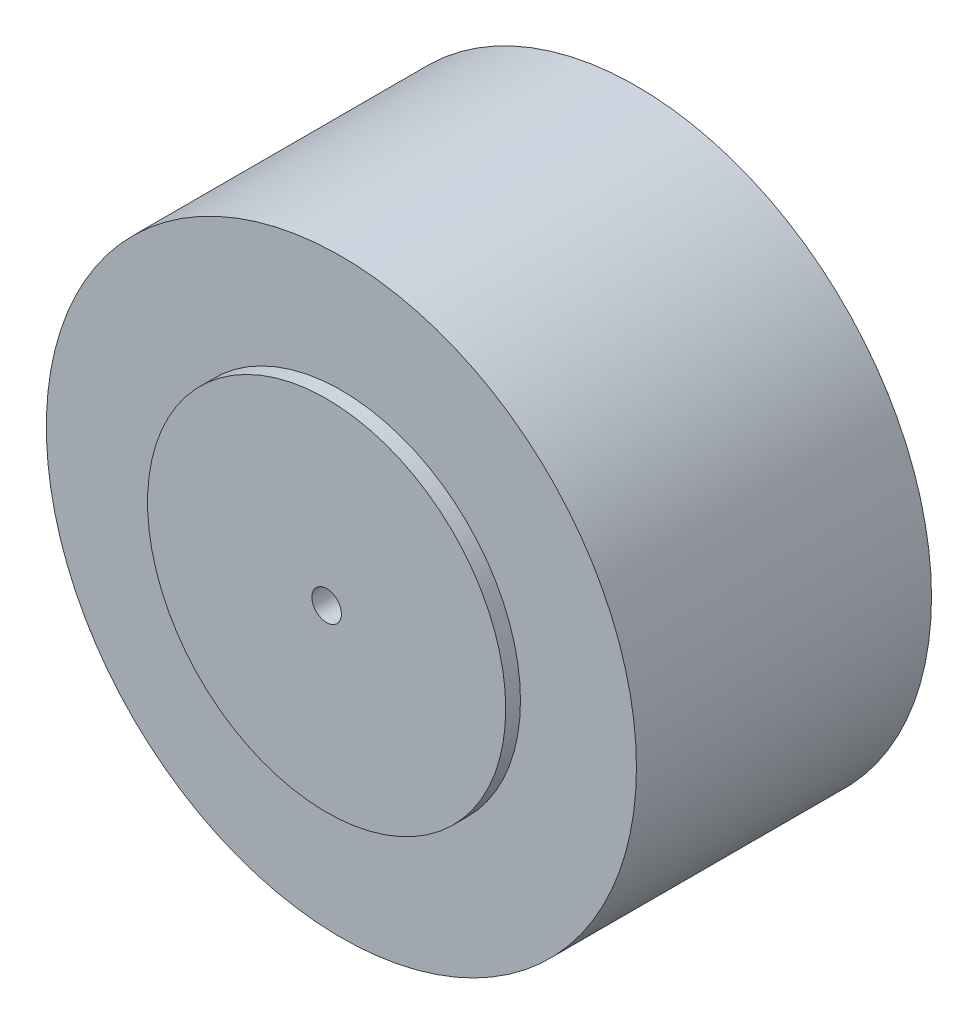
from build123d import *

# Parameters (mm, degrees)
SKETCH1_R           = 12.7
BOSS_EXTRUDE1_DEPTH = 12.7
SKETCH2_R           = 7.70834565
BOSS_EXTRUDE2_DEPTH = 0.635
SKETCH3_R           = 7.677981209
BOSS_EXTRUDE3_DEPTH = 0.635
SKETCH4_R           = 0.635
CUT_EXTRUDE1_DEPTH  = 1.27
SKETCH5_R           = 0.635
CUT_EXTRUDE2_DEPTH  = 1.27


with BuildPart() as part:
    # Sketch1 → Boss-Extrude1 (new body)
    with BuildSketch(Plane.XY):
        Circle(SKETCH1_R)
    extrude(amount=BOSS_EXTRUDE1_DEPTH)

    # Sketch2 → Boss-Extrude2 (add)
    with BuildSketch(Plane.XY.offset(12.7)):
        Circle(SKETCH2_R)
    extrude(amount=BOSS_EXTRUDE2_DEPTH)

    # Sketch3 → Boss-Extrude3 (add)
    with BuildSketch(Plane(origin=(0, 0, 0), x_dir=(-1, 0, 0), z_dir=(0, 0, -1))):
        Circle(SKETCH3_R)
    extrude(amount=BOSS_EXTRUDE3_DEPTH)

    # Sketch4 → Cut-Extrude1 (cut)
    with BuildSketch(Plane.XY.offset(13.335)):
        Circle(SKETCH4_R)
    extrude(amount=-CUT_EXTRUDE1_DEPTH, mode=Mode.SUBTRACT)

    # Sketch5 → Cut-Extrude2 (cut)
    with BuildSketch(Plane(origin=(0, 0, -0.635), x_dir=(-1, 0, 0), z_dir=(0, 0, -1))):
        Circle(SKETCH5_R)
    extrude(amount=-CUT_EXTRUDE2_DEPTH, mode=Mode.SUBTRACT)


solid = part.part
